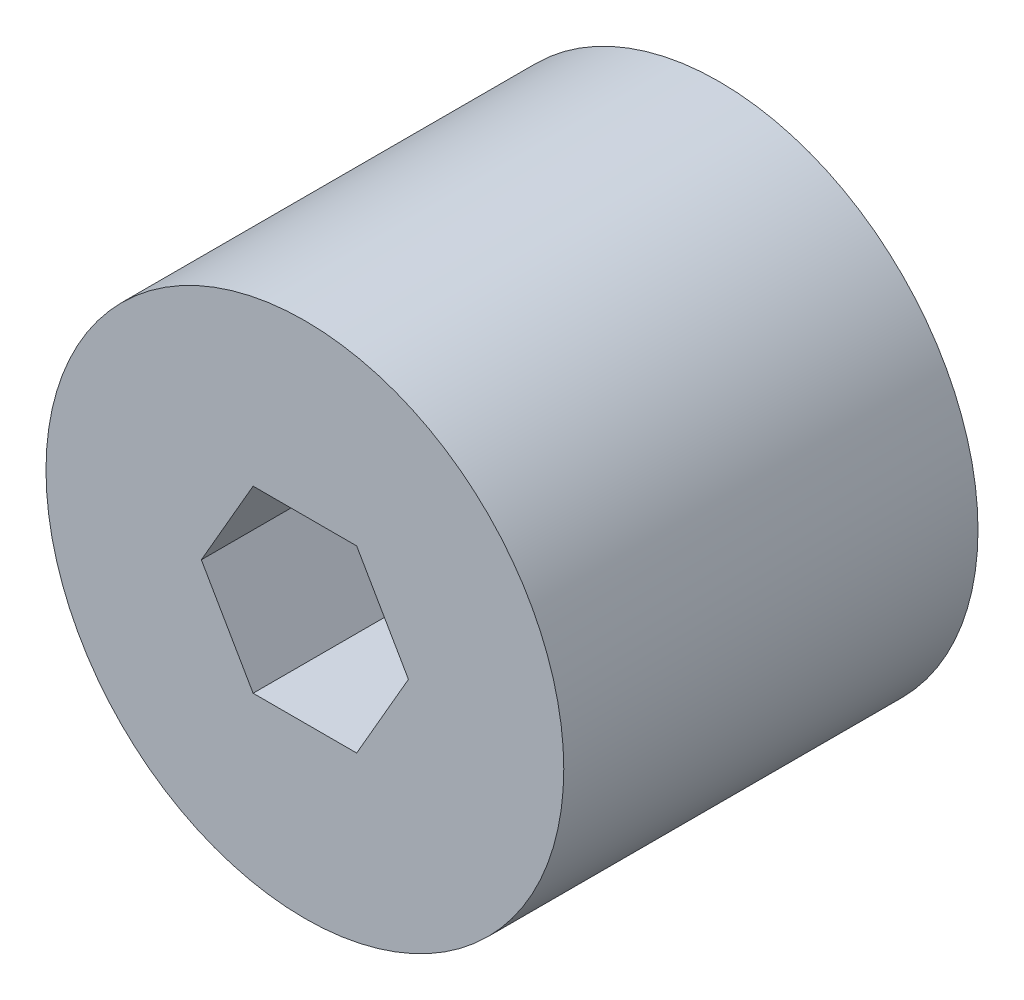
from build123d import *

# Parameters (mm, degrees)
SKETCH1_R           = 15.875
BOSS_EXTRUDE1_DEPTH = 25.4
CUT_EXTRUDE1_DEPTH  = 26.4


with BuildPart() as part:
    # Sketch1 → Boss-Extrude1 (new body)
    with BuildSketch(Plane.XY):
        Circle(SKETCH1_R)
    extrude(amount=BOSS_EXTRUDE1_DEPTH)

    # Sketch3 → Cut-Extrude1 (cut, through all)
    with BuildSketch(Plane.XY.offset(25.4)):
        Polygon((6.35, 0), (3.175, 5.499261314), (-3.175, 5.499261314), (-6.35, 0), (-3.175, -5.499261314), (3.175, -5.499261314), align=None)
    extrude(amount=-CUT_EXTRUDE1_DEPTH, mode=Mode.SUBTRACT)


solid = part.part
